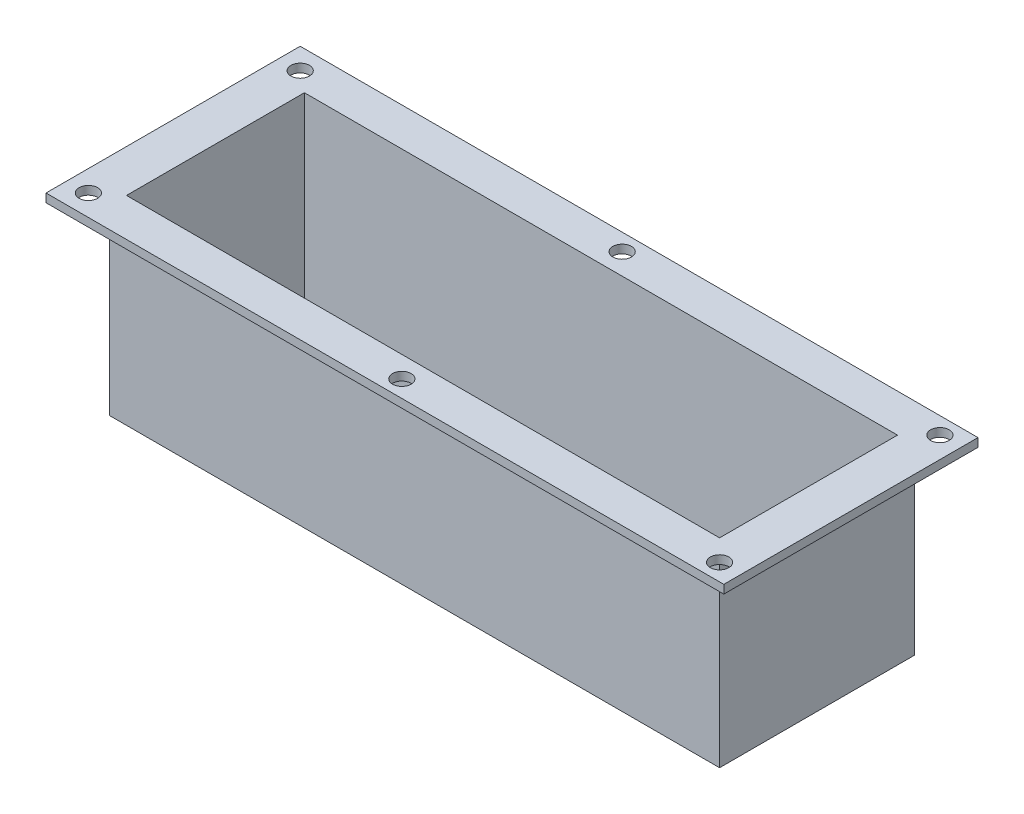
from build123d import *

# Parameters (mm, degrees)
SKETCH3_W           = 182.88
SKETCH3_H           = 58.42
BOSS_EXTRUDE1_DEPTH = 57.15
SKETCH4_W           = 203.2
SKETCH4_H           = 76.2
BOSS_EXTRUDE2_DEPTH = 2.54
SKETCH5_W           = 177.8
SKETCH5_H           = 53.34
CUT_EXTRUDE1_DEPTH  = 54.61
SKETCH6_R           = 2.7813
CUT_EXTRUDE2_DEPTH  = 53.34
SKETCH7_R           = 3.175
CUT_EXTRUDE3_DEPTH  = 3.54


with BuildPart() as part:
    # Sketch3 → Boss-Extrude1 (new body)
    with BuildSketch(Plane(origin=(0, 0, 0), x_dir=(1, 0, 0), z_dir=(0, 1, 0))):
        Rectangle(SKETCH3_W, SKETCH3_H)
    extrude(amount=-BOSS_EXTRUDE1_DEPTH)

    # Sketch4 → Boss-Extrude2 (add)
    with BuildSketch(Plane(origin=(0, 0, 0), x_dir=(1, 0, 0), z_dir=(0, 1, 0))):
        Rectangle(SKETCH4_W, SKETCH4_H)
    extrude(amount=-BOSS_EXTRUDE2_DEPTH)

    # Sketch5 → Cut-Extrude1 (cut)
    with BuildSketch(Plane(origin=(0, 0, 0), x_dir=(1, 0, 0), z_dir=(0, 1, 0))):
        Rectangle(SKETCH5_W, SKETCH5_H)
    extrude(amount=-CUT_EXTRUDE1_DEPTH, mode=Mode.SUBTRACT)

    # Sketch6 → Cut-Extrude2 (cut)
    with BuildSketch(Plane(origin=(0, 0, 0), x_dir=(1, 0, 0), z_dir=(0, 1, 0))):
        with Locations((-95.25, 31.75)):
            Circle(SKETCH6_R)
        with Locations((0, 33.02)):
            Circle(SKETCH6_R)
        with Locations((95.25, 33.02)):
            Circle(SKETCH6_R)
        with Locations((95.25, -33.02)):
            Circle(SKETCH6_R)
        with Locations((0, -33.02)):
            Circle(SKETCH6_R)
        with Locations((-95.25, -31.75)):
            Circle(SKETCH6_R)
    extrude(amount=-CUT_EXTRUDE2_DEPTH, mode=Mode.SUBTRACT)

    # Sketch7 → Cut-Extrude3 (cut, through all)
    with BuildSketch(Plane(origin=(0, -54.61, 0), x_dir=(1, 0, 0), z_dir=(0, 1, 0))):
        with Locations((-63.5, 12.7)):
            Circle(SKETCH7_R)
        with Locations((-50.8, 0)):
            Circle(SKETCH7_R)
        with Locations((-63.5, -12.7)):
            Circle(SKETCH7_R)
        with Locations((-76.2, 0)):
            Circle(SKETCH7_R)
    extrude(amount=-CUT_EXTRUDE3_DEPTH, mode=Mode.SUBTRACT)


solid = part.part
